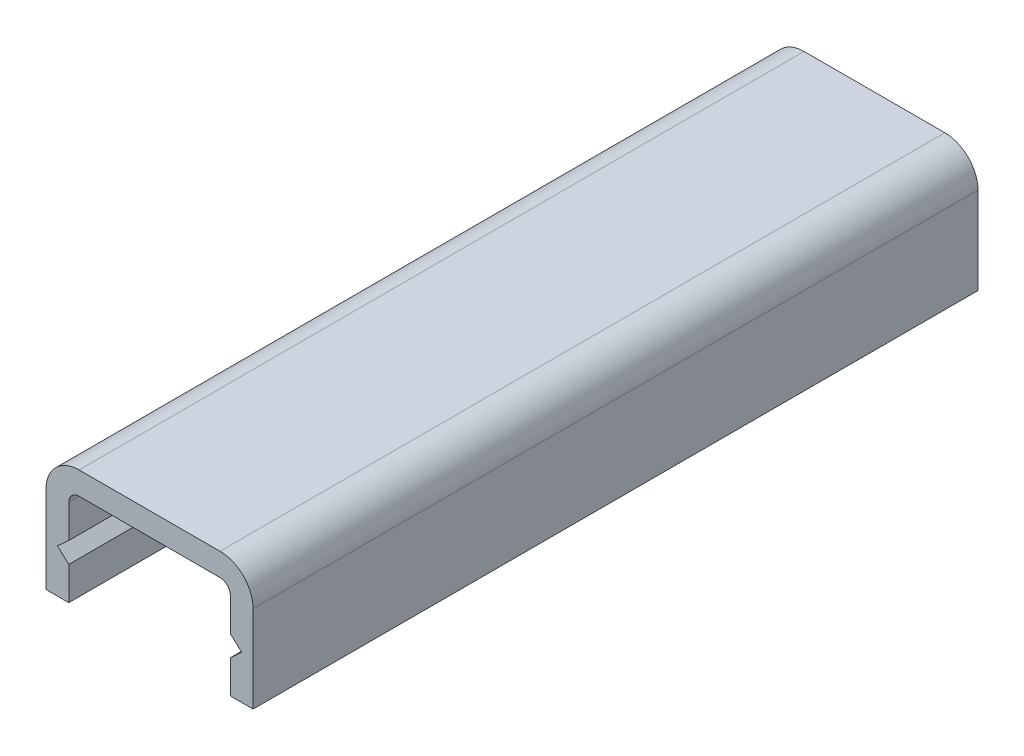
from build123d import *

# Parameters (mm, degrees)
EXTRUSION1_DEPTH = 35


with BuildPart() as part:
    # Esquisse1 → Extrusion1 (new body)
    with BuildSketch(Plane.XY):
        with BuildLine():
            Line((1.6, 5.8), (8.4, 5.8))
            ThreePointArc((8.4, 5.8), (9.53137085, 5.33137085), (10, 4.2))
            Line((10, 4.2), (10, 0))
            Line((10, 0), (8.9, 0))
            Line((8.9, 0), (8.9, 1.6))
            Line((8.9, 1.6), (9.45, 2.1))
            Line((9.45, 2.1), (8.9, 2.6))
            Line((8.9, 2.6), (8.9, 4.2))
            ThreePointArc((8.9, 4.2), (8.753553391, 4.553553391), (8.4, 4.7))
            Line((8.4, 4.7), (1.6, 4.7))
            ThreePointArc((1.6, 4.7), (1.246446609, 4.553553391), (1.1, 4.2))
            Line((1.1, 4.2), (1.1, 2.6))
            Line((1.1, 2.6), (0.55, 2.1))
            Line((0.55, 2.1), (1.1, 1.6))
            Line((1.1, 1.6), (1.1, 0))
            Line((1.1, 0), (0, 0))
            Line((0, 0), (0, 4.2))
            ThreePointArc((0, 4.2), (0.46862915, 5.33137085), (1.6, 5.8))
        make_face()
    extrude(amount=EXTRUSION1_DEPTH)


solid = part.part
